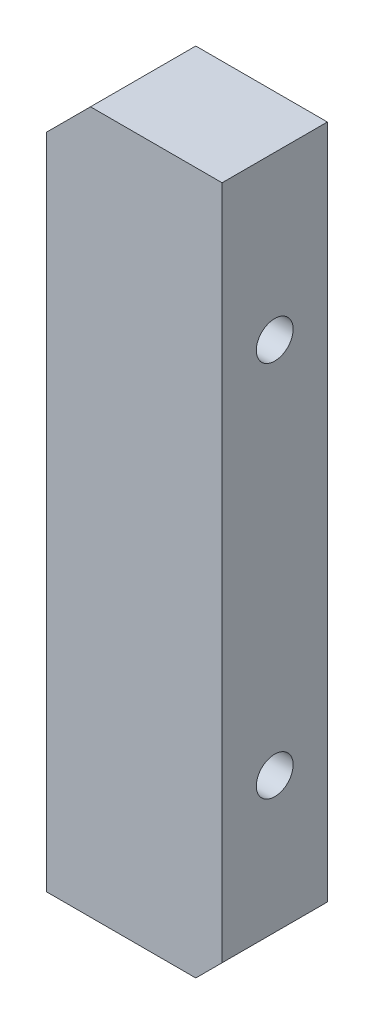
from build123d import *

# Parameters (mm, degrees)
BOSS_EXTRUDE1_DEPTH       = 12
M5X0_8_TAPPED_HOLE1_D     = 4.2
M5X0_8_TAPPED_HOLE1_DEPTH = 14
M5X0_8_TAPPED_HOLE1_TIP   = 1.2618073
M5X0_8_TAPPED_HOLE2_D     = 4.2
M5X0_8_TAPPED_HOLE2_DEPTH = 14
M5X0_8_TAPPED_HOLE2_TIP   = 1.2618073


with BuildPart() as part:
    # Sketch1 → Boss-Extrude1 (new body)
    with BuildSketch(Plane.XY):
        Polygon((0, 75), (5, 80), (20, 80), (20, 3), (17, 0), (0, 0), align=None)
    extrude(amount=BOSS_EXTRUDE1_DEPTH)

    # M5x0.8 Tapped Hole1
    with Locations(Plane.XZ):
        with Locations((8, 6)):
            Hole(M5X0_8_TAPPED_HOLE1_D / 2, depth=M5X0_8_TAPPED_HOLE1_DEPTH)
            with Locations((0, 0, -(M5X0_8_TAPPED_HOLE1_DEPTH + M5X0_8_TAPPED_HOLE1_TIP / 2))):  # 118° drill point
                Cone(0, M5X0_8_TAPPED_HOLE1_D / 2, M5X0_8_TAPPED_HOLE1_TIP, mode=Mode.SUBTRACT)

    # M5x0.8 Tapped Hole2
    with Locations(Plane(origin=(20, 0, 0), x_dir=(0, 0, -1), z_dir=(1, 0, 0))):
        with Locations((-6, 18.5), (-6, 61.5)):
            Hole(M5X0_8_TAPPED_HOLE2_D / 2, depth=M5X0_8_TAPPED_HOLE2_DEPTH)
            with Locations((0, 0, -(M5X0_8_TAPPED_HOLE2_DEPTH + M5X0_8_TAPPED_HOLE2_TIP / 2))):  # 118° drill point
                Cone(0, M5X0_8_TAPPED_HOLE2_D / 2, M5X0_8_TAPPED_HOLE2_TIP, mode=Mode.SUBTRACT)


solid = part.part
